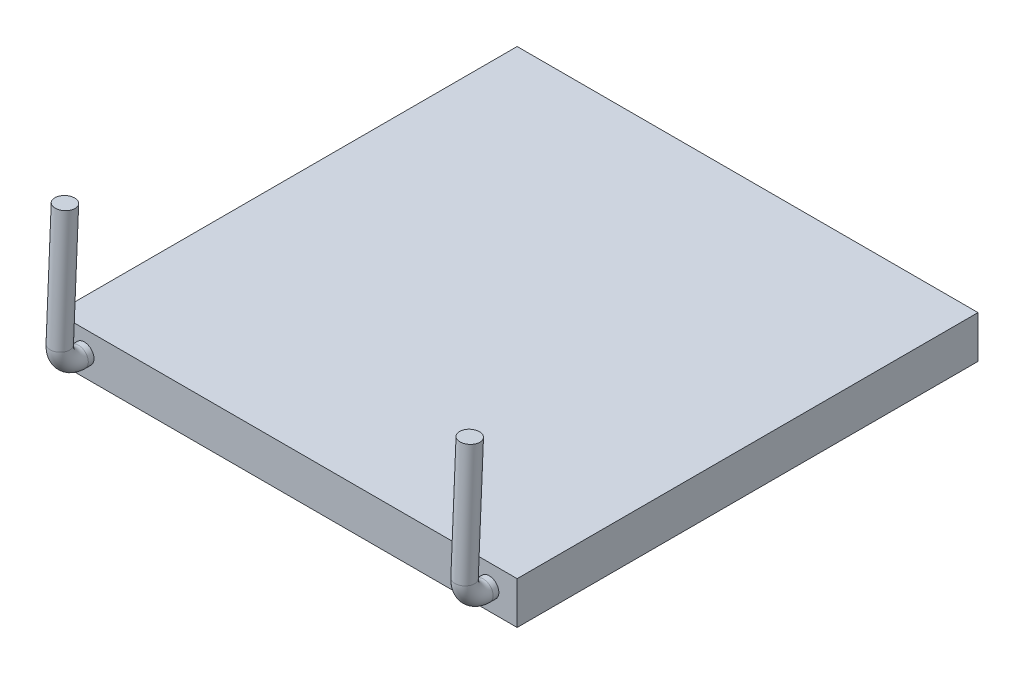
from build123d import *

# Parameters (mm, degrees)
SKETCH1_W           = 40.3
SKETCH1_H           = 40.3
BOSS_EXTRUDE1_DEPTH = 3.7
SKETCH3_R           = 0.85
BOSS_EXTRUDE2_DEPTH = 0.5
SKETCH5_R           = 0.85
SKETCH6_R           = 0.85
BOSS_EXTRUDE3_DEPTH = 10.5


with BuildPart() as part:
    # Sketch1 → Boss-Extrude1 (new body)
    with BuildSketch(Plane(origin=(0, 0, 0), x_dir=(1, 0, 0), z_dir=(0, 1, 0))):
        Rectangle(SKETCH1_W, SKETCH1_H)
    extrude(amount=BOSS_EXTRUDE1_DEPTH)

    # Sketch3 → Boss-Extrude2 (add)
    with BuildSketch(Plane.XY.offset(20.15)):
        with Locations((-17.7, 1.85)):
            Circle(SKETCH3_R)
    boss_extrude2 = extrude(amount=BOSS_EXTRUDE2_DEPTH)

    # Sweep1: sweep along a path in Sketch4
    with BuildLine(Plane.ZY.offset(17.7)) as sweep1_path:
        ThreePointArc((20.65, 1.85), (21.842957341, 2.359410226), (22.3, 3.573394576))
    # Sketch5 → Sweep1 (sweep)
    with BuildSketch(Plane.XY.offset(20.65)):
        with Locations((-17.7, 1.85)):
            Circle(SKETCH5_R)
    sweep1 = sweep(path=sweep1_path.line)

    # Sketch6 → Boss-Extrude3 (add)
    with BuildSketch(Plane(origin=(0, 2.597654528, -0.113087301), x_dir=(1, 0, 0), z_dir=(0, 0.9990537233687481, -0.04349319283567326))):
        with Locations((-17.7, -22.434316371)):
            Circle(SKETCH6_R)
    boss_extrude3 = extrude(amount=BOSS_EXTRUDE3_DEPTH)

    # Mirror1: Boss-Extrude2, Sweep1, Boss-Extrude3 across plane
    add(boss_extrude2.mirror(Plane(origin=(0, 0, 0), x_dir=(0, 0, 1), z_dir=(1, 0, 0))))
    add(sweep1.mirror(Plane(origin=(0, 0, 0), x_dir=(0, 0, 1), z_dir=(1, 0, 0))))
    add(boss_extrude3.mirror(Plane(origin=(0, 0, 0), x_dir=(0, 0, 1), z_dir=(1, 0, 0))))


solid = part.part
